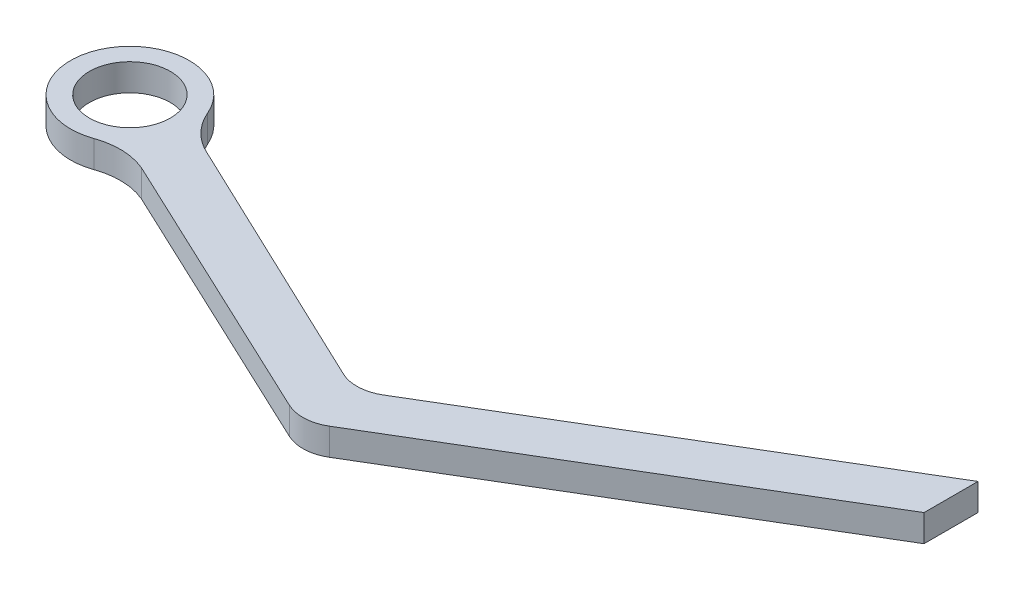
from build123d import *

# Parameters (mm, degrees)
SKETCH1_R           = 3
BOSS_EXTRUDE1_DEPTH = 2


with BuildPart() as part:
    # Sketch1 → Boss-Extrude1 (new body)
    with BuildSketch(Plane(origin=(0, 0, 0), x_dir=(1, 0, 0), z_dir=(0, 1, 0))):
        with BuildLine():
            Line((25.842346039, -10.014425763), (6.693666426, -0.919624764))
            ThreePointArc((6.693666426, -0.919624764), (5.113423812, 0.145118135), (4.046267677, 1.723732067))
            ThreePointArc((4.046267677, 1.723732067), (-4.027578724, 1.766958961), (1.471755352, -4.144571212))
            ThreePointArc((1.471755352, -4.144571212), (3.304406882, -3.858859691), (5.115110957, -4.26084658))
            Line((5.115110957, -4.26084658), (25.845891994, -14.02203976))
            ThreePointArc((25.845891994, -14.02203976), (27.271804068, -14.304213396), (28.662988426, -13.882961353))
            Line((28.662988426, -13.882961353), (56.254370384, 2.608150475))
            Line((56.254370384, 2.608150475), (56.254370384, 6.608150475))
            Line((56.254370384, 6.608150475), (28.668534032, -9.879646796))
            ThreePointArc((28.668534032, -9.879646796), (27.272327122, -10.30114258), (25.842346039, -10.014425763))
        make_face()
        Circle(SKETCH1_R, mode=Mode.SUBTRACT)
    extrude(amount=BOSS_EXTRUDE1_DEPTH)


solid = part.part
